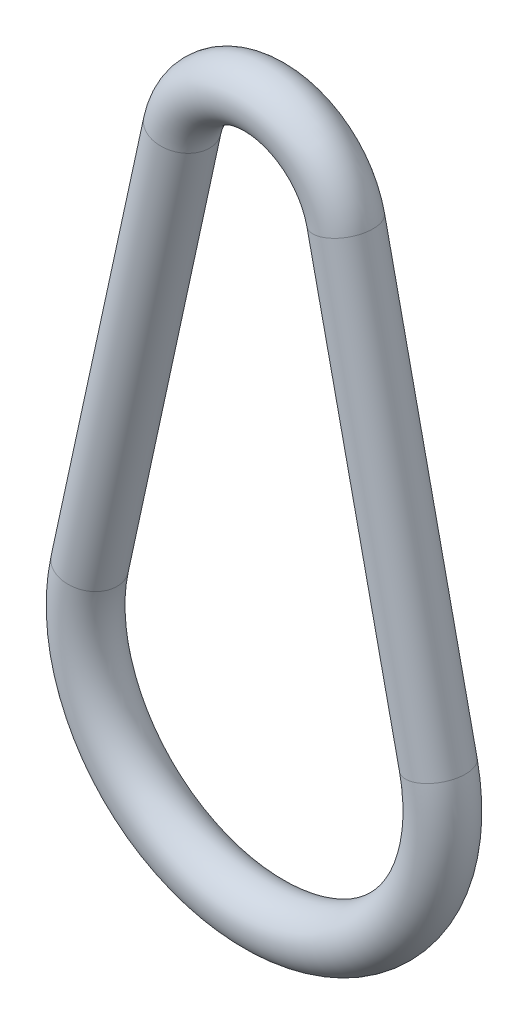
from build123d import *

# Parameters (mm, degrees)
SKETCH2_R = 5


with BuildPart() as part:
    # Sweep1: sweep along a path in Sketch1
    with BuildLine(Plane.XY) as sweep1_path:
        Line((-14.657415998, 83.1875), (-31.26915413, 6.8))
        ThreePointArc((-31.26915413, 6.8), (0, -32), (31.26915413, 6.8))
        Line((31.26915413, 6.8), (14.657415998, 83.1875))
        ThreePointArc((14.657415998, 83.1875), (0, 95), (-14.657415998, 83.1875))
    # Sketch2 → Sweep1 (sweep)
    with BuildSketch(Plane(origin=(-31.26915413, 6.8, 0), x_dir=(-0.977161067, 0.2125, 0), z_dir=(-0.2125, -0.977161067, 0))):
        Circle(SKETCH2_R)
    sweep(path=sweep1_path.line)


solid = part.part
